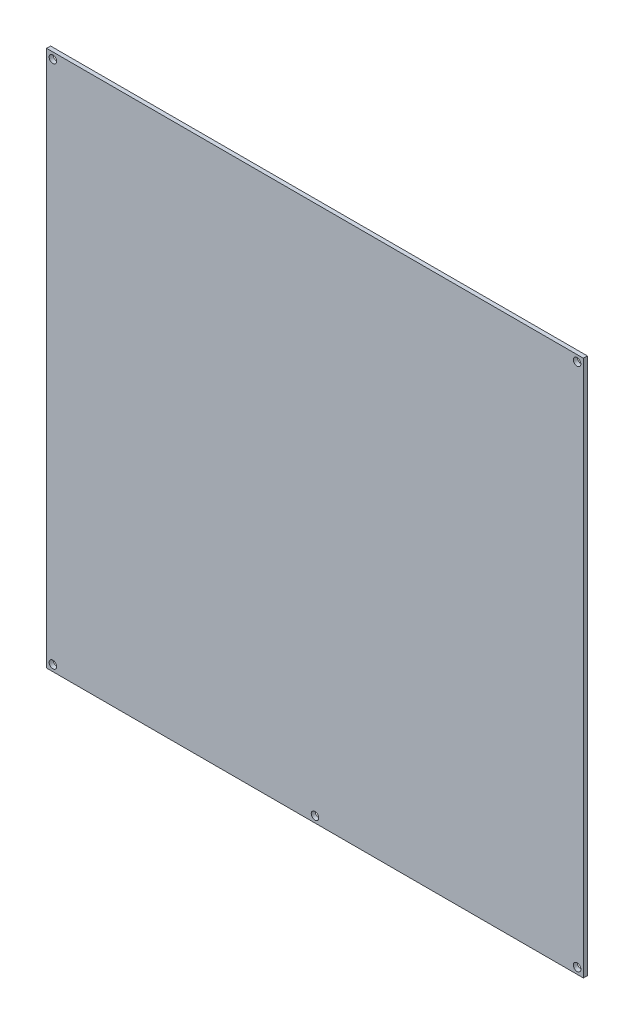
from build123d import *

# Parameters (mm, degrees)
SKETCH1_W           = 214
SKETCH1_H           = 214
SKETCH1_R           = 1.5
BOSS_EXTRUDE1_DEPTH = 1.6


with BuildPart() as part:
    # Sketch1 → Boss-Extrude1 (new body)
    with BuildSketch(Plane.XY):
        Rectangle(SKETCH1_W, SKETCH1_H)
        with Locations((-104.5, 104.5)):
            Circle(SKETCH1_R, mode=Mode.SUBTRACT)
        with Locations((104.5, 104.5)):
            Circle(SKETCH1_R, mode=Mode.SUBTRACT)
        with Locations((0, -104.5)):
            Circle(SKETCH1_R, mode=Mode.SUBTRACT)
        with Locations((104.5, -104.5)):
            Circle(SKETCH1_R, mode=Mode.SUBTRACT)
        with Locations((-104.5, -104.5)):
            Circle(SKETCH1_R, mode=Mode.SUBTRACT)
    extrude(amount=BOSS_EXTRUDE1_DEPTH)


solid = part.part
